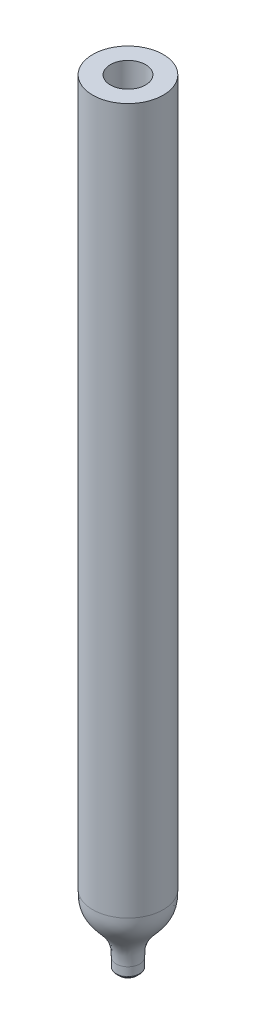
from build123d import *

# Parameters (mm, degrees)
CHAMFER1_SIZE = 0.25
FILLET1_R     = 0.1


with BuildPart() as part:
    # Sketch1 → Revolve1 (revolve)
    with BuildSketch(Plane.XY):
        with BuildLine():
            Line((1.5, 61), (3, 61))
            Line((3, 61), (3, 1))
            add(Edge.make_bspline(
                [(1, -4), (1, -2.852326224), (1, -1.704652447), (3, -1.295347553), (3, -0.147673776), (3, 1)],
                knots=[0, 0, 0, 0, 0, 0, 1, 1, 1, 1, 1, 1], degree=5))
            Line((1, -4), (1, -5))
            Line((1, -5), (0.25, -5))
            Line((0.25, -5), (0.25, -4))
            add(Edge.make_bspline(
                [(0.25, -4), (0.25, -3.874328316), (0.348, -1.569029575), (1.407157895, -1.561541747), (1.5, -0.081983242), (1.5, 0)],
                knots=[0, 0, 0, 0, 0.05, 0.95, 1, 1, 1, 1], degree=3))
            Line((1.5, 0), (1.5, 61))
        make_face()
    revolve(axis=Axis((0, 0, 0), (0, -1, 0)))

    # Chamfer1
    chamfer1_edges = [part.edges().sort_by_distance(p)[0] for p in [
        (-1, -5, 0),
    ]]
    chamfer(chamfer1_edges, length=CHAMFER1_SIZE)

    # Fillet1
    fillet1_edges = [part.edges().sort_by_distance(p)[0] for p in [
        (-1, -4.75, 0),
    ]]
    fillet(fillet1_edges, radius=FILLET1_R)


solid = part.part
